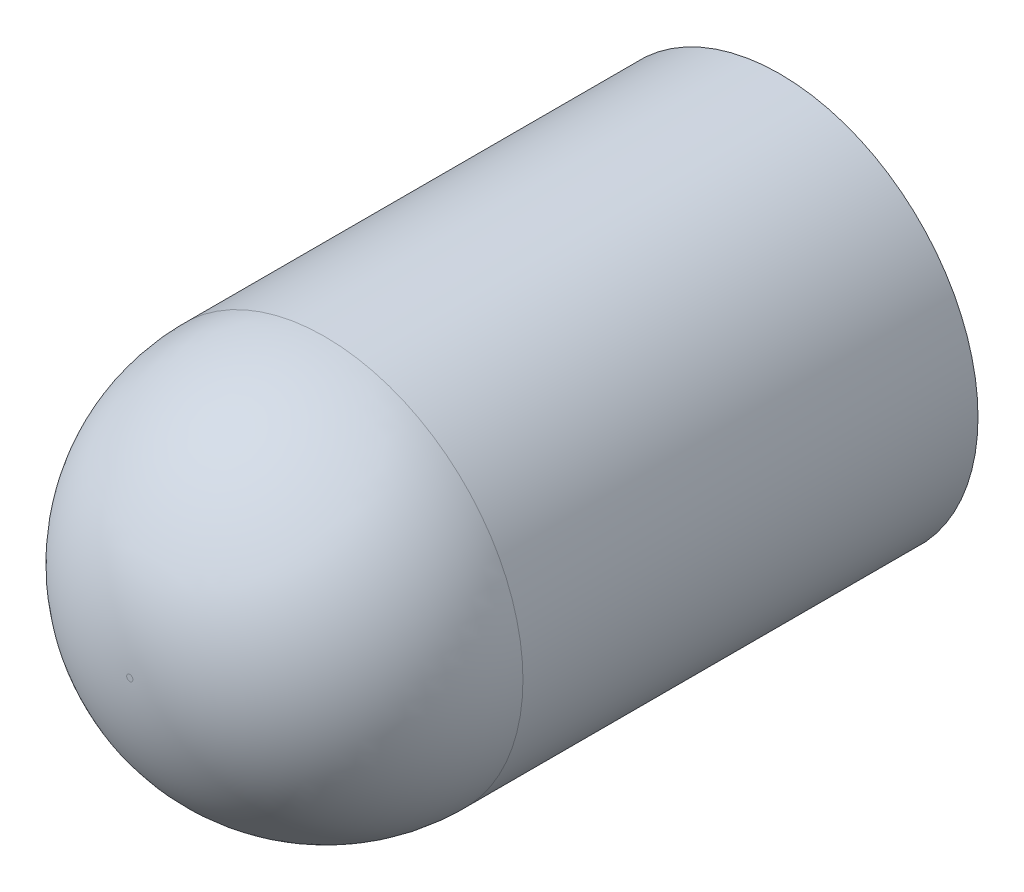
from build123d import *

# Parameters (mm, degrees)
SKETCH1_R           = 3.048
BOSS_EXTRUDE1_DEPTH = 10
FILLET2_R           = 3


with BuildPart() as part:
    # Sketch1 → Boss-Extrude1 (new body)
    with BuildSketch(Plane.XY):
        Circle(SKETCH1_R)
    extrude(amount=BOSS_EXTRUDE1_DEPTH)

    # Fillet2
    fillet2_edges = [part.edges().sort_by_distance(p)[0] for p in [
        (-3.048, 0, 10),
    ]]
    fillet(fillet2_edges, radius=FILLET2_R)


solid = part.part
